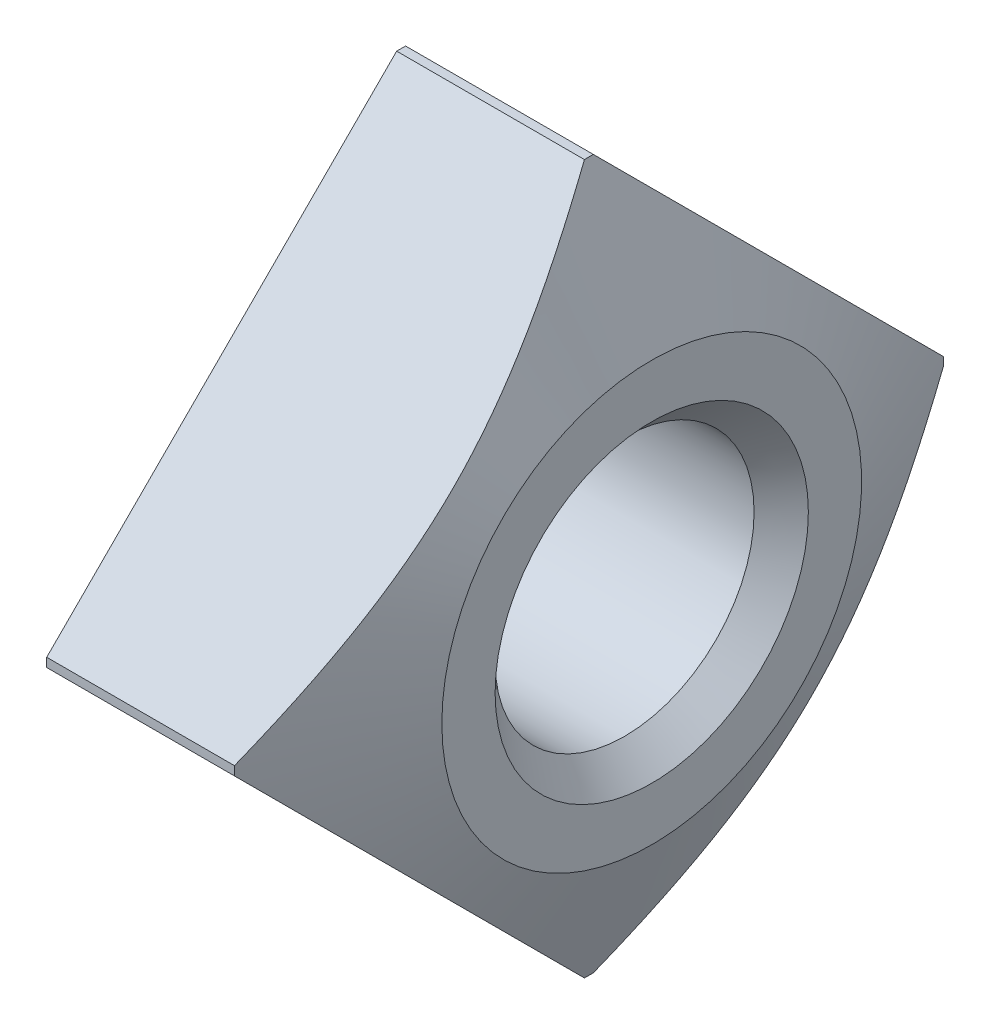
from build123d import *

# Parameters (mm, degrees)
SKETCH2_W          = 32
SKETCH2_H          = 32
CUT_EXTRUDE1_DEPTH = 4


with BuildPart() as part:
    # Sketch1 → Revolve1 (revolve)
    with BuildSketch(Plane.XY):
        Polygon((0, 0), (0, 5.656854249), (2.996951225, 5.656854249), (4, 3.35), (4, 0), align=None)
    revolve(axis=Axis((4, 0, 0), (-1, 0, 0)))

    # Sketch2 → Cut-Extrude1 (cut)
    with BuildSketch(Plane(origin=(0, 0, 0), x_dir=(0, 0, -1), z_dir=(1, 0, 0))):
        Rectangle(SKETCH2_W, SKETCH2_H)
        Polygon((-5.727564928, 0), (0, -5.727564928), (5.727564928, 0), (0, 5.727564928), align=None, mode=Mode.SUBTRACT)
    extrude(amount=CUT_EXTRUDE1_DEPTH, mode=Mode.SUBTRACT)

    # Sketch3 → Cut-Revolve1 (revolve, cut)
    with BuildSketch(Plane.XY):
        Polygon((0, 0), (0, 2.5), (0.433, 2.067), (3.567, 2.067), (4, 2.5), (4, 0), align=None)
    revolve(axis=Axis((4, 0, 0), (-1, 0, 0)), mode=Mode.SUBTRACT)


solid = part.part
